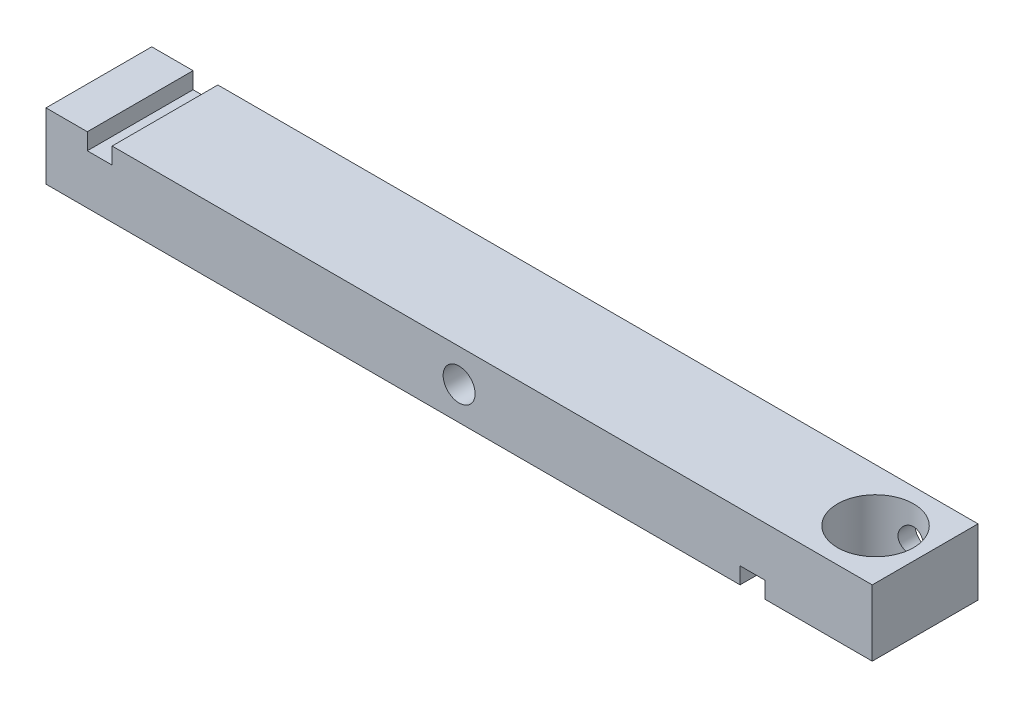
from build123d import *

# Parameters (mm, degrees)
SKETCH1_W                    = 127
SKETCH1_H                    = 10.16
BOSS_EXTRUDE1_DEPTH          = 8.128
F_10_0_1935_DIAMETER_HOLE2_D = 4.9149
SKETCH6_W                    = 3.81
SKETCH6_H                    = 2.54
CUT_EXTRUDE1_DEPTH           = 16.256
HOLE1_D                      = 11.684
HOLE2_D                      = 4.064
HOLE2_DEPTH                  = 6.906051222
HOLE2_TIP                    = 1.220948778


with BuildPart() as part:
    # Sketch1 → Boss-Extrude1 (new body, symmetric)
    with BuildSketch(Plane.XY):
        Rectangle(SKETCH1_W, SKETCH1_H)
    extrude(amount=BOSS_EXTRUDE1_DEPTH, both=True)

    # #10 (0.1935) Diameter Hole2 (through all)
    with Locations(Plane.XY.offset(8.128)):
        with Locations((0, 0)):
            Hole(F_10_0_1935_DIAMETER_HOLE2_D / 2)

    # Sketch6 → Cut-Extrude1 (cut)
    with BuildSketch(Plane.XY.offset(8.128)):
        with Locations((-55.245, 3.81)):
            Rectangle(SKETCH6_W, SKETCH6_H)
        with Locations((45.085, -3.81)):
            Rectangle(SKETCH6_W, SKETCH6_H)
    extrude(amount=-CUT_EXTRUDE1_DEPTH, mode=Mode.SUBTRACT)

    # Hole1 (through all)
    with Locations(Plane(origin=(0, 5.08, 0), x_dir=(1, 0, 0), z_dir=(0, 1, 0))):
        with Locations((55.88, 0)):
            Hole(HOLE1_D / 2)

    # Hole2
    with Locations(Plane(origin=(0, 0, -8.128), x_dir=(-1, 0, 0), z_dir=(0, 0, -1))):
        with Locations((-55.88, 0)):
            Hole(HOLE2_D / 2, depth=HOLE2_DEPTH)
            with Locations((0, 0, -(HOLE2_DEPTH + HOLE2_TIP / 2))):  # 118° drill point
                Cone(0, HOLE2_D / 2, HOLE2_TIP, mode=Mode.SUBTRACT)


solid = part.part
